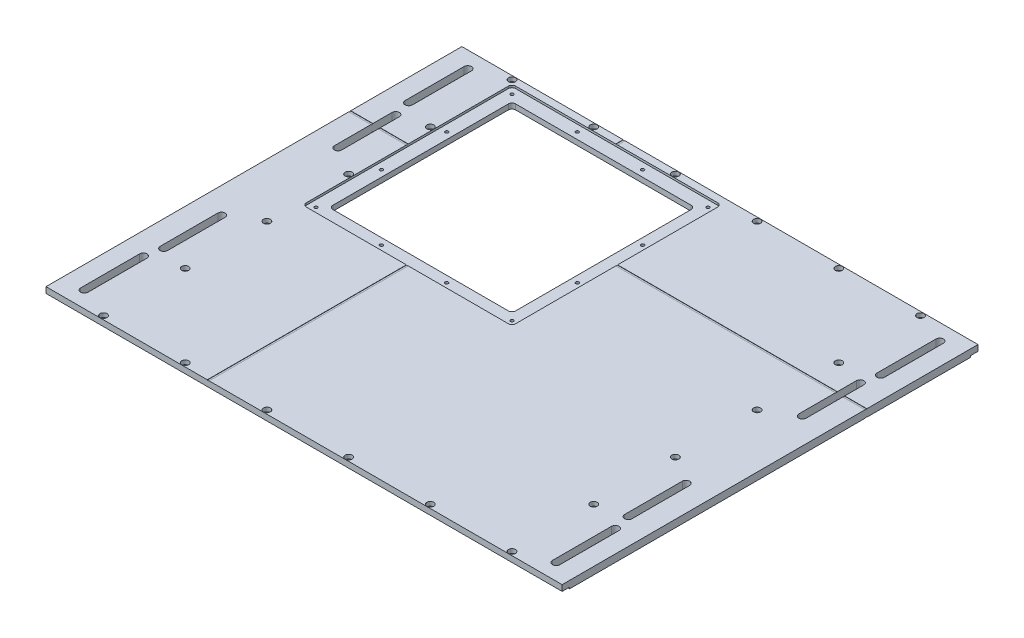
from build123d import *

# Parameters (mm, degrees)
SKETCH1_W                                      = 444.5
SKETCH1_H                                      = 358.14
BOSS_EXTRUDE1_DEPTH                            = 6.35
CUT_EXTRUDE1_DEPTH                             = 6.35
CUT_EXTRUDE2_DEPTH                             = 1.8542
CBORE_FOR_6_SOCKET_HEAD_CAP_SCREW1_D           = 3.6576
CBORE_FOR_6_SOCKET_HEAD_CAP_SCREW1_CBORE_D     = 5.999999938
CBORE_FOR_6_SOCKET_HEAD_CAP_SCREW1_CBORE_DEPTH = 3.5052
TAP_DRILL_FOR_6_32_TAP1_D                      = 2.7051
SKETCH21_W                                     = 345.44
SKETCH21_H                                     = 345.44
CUT_EXTRUDE3_DEPTH                             = 1.27
CUT_EXTRUDE4_DEPTH                             = 7.35
CUT_EXTRUDE6_DEPTH                             = 0.254
CUT_EXTRUDE7_DEPTH                             = 0.254


with BuildPart() as part:
    # Sketch1 → Boss-Extrude1 (new body)
    with BuildSketch(Plane(origin=(0, 0, 0), x_dir=(1, 0, 0), z_dir=(0, 1, 0))):
        with Locations((222.25, 179.07)):
            Rectangle(SKETCH1_W, SKETCH1_H)
    extrude(amount=BOSS_EXTRUDE1_DEPTH)

    # Sketch2 → Cut-Extrude1 (cut)
    with BuildSketch(Plane(origin=(0, 6.35, 0), x_dir=(1, 0, 0), z_dir=(0, 1, 0))):
        with BuildLine():
            Line((64.135, 182.88), (215.265, 182.88))
            ThreePointArc((215.265, 182.88), (217.51006403, 183.80993597), (218.44, 186.055))
            Line((218.44, 186.055), (218.44, 337.185))
            ThreePointArc((218.44, 337.185), (217.51006403, 339.43006403), (215.265, 340.36))
            Line((215.265, 340.36), (64.135, 340.36))
            ThreePointArc((64.135, 340.36), (61.88993597, 339.43006403), (60.96, 337.185))
            Line((60.96, 337.185), (60.96, 186.055))
            ThreePointArc((60.96, 186.055), (61.88993597, 183.80993597), (64.135, 182.88))
        make_face()
    extrude(amount=-CUT_EXTRUDE1_DEPTH, mode=Mode.SUBTRACT)

    # Sketch3 → Cut-Extrude2 (cut)
    with BuildSketch(Plane(origin=(0, 6.35, 0), x_dir=(1, 0, 0), z_dir=(0, 1, 0))):
        with BuildLine():
            Line((52.705, 171.45), (226.695, 171.45))
            ThreePointArc((226.695, 171.45), (228.94006403, 172.37993597), (229.87, 174.625))
            Line((229.87, 174.625), (229.87, 348.615))
            ThreePointArc((229.87, 348.615), (228.94006403, 350.86006403), (226.695, 351.79))
            Line((226.695, 351.79), (52.705, 351.79))
            ThreePointArc((52.705, 351.79), (50.45993597, 350.86006403), (49.53, 348.615))
            Line((49.53, 348.615), (49.53, 174.625))
            ThreePointArc((49.53, 174.625), (50.45993597, 172.37993597), (52.705, 171.45))
        make_face()
    extrude(amount=-CUT_EXTRUDE2_DEPTH, mode=Mode.SUBTRACT)

    # CBORE for #6 Socket Head Cap Screw1 (through all)
    with Locations(Plane(origin=(0, 6.35, 0), x_dir=(1, 0, 0), z_dir=(0, 1, 0))):
        with Locations((46.355, 354.965), (116.713, 354.965), (187.071, 354.965), (398.145, 354.965), (327.787, 354.965), (257.429, 354.965), (398.145, 3.175), (327.787, 3.175), (257.429, 3.175), (187.071, 3.175), (116.713, 3.175), (46.355, 3.175), (398.145, 284.607), (398.145, 214.249), (398.145, 143.891), (398.145, 73.533), (46.355, 73.533), (46.355, 143.891), (46.355, 214.249), (46.355, 284.607)):
            CounterBoreHole(CBORE_FOR_6_SOCKET_HEAD_CAP_SCREW1_D / 2, CBORE_FOR_6_SOCKET_HEAD_CAP_SCREW1_CBORE_D / 2, CBORE_FOR_6_SOCKET_HEAD_CAP_SCREW1_CBORE_DEPTH)

    # Tap Drill for #6-32 Tap1 (through all)
    with Locations(Plane(origin=(249.462488364, 4.4958, -88.952448836), x_dir=(0, 0, 1), z_dir=(0, 1, 0))):
        with Locations((-257.059051164, -194.153988364), (-88.276051164, -194.153988364), (-144.537051164, -194.153988364), (-200.798051164, -194.153988364), (-257.059051164, -137.892988364), (-88.276051164, -137.892988364), (-88.276051164, -81.631988364), (-88.276051164, -25.370988364), (-144.537051164, -25.370988364), (-200.798051164, -25.370988364), (-257.059051164, -25.370988364), (-257.059051164, -81.631988364)):
            Hole(TAP_DRILL_FOR_6_32_TAP1_D / 2)

    # Sketch21 → Cut-Extrude3 (cut)
    with BuildSketch(Plane.XZ):
        Polygon((444.5, -358.14), (444.5, -351.79), (401.32, -351.79), (401.32, -6.35), (444.5, -6.35), (444.5, 0), (0, 0), (0, -6.35), (43.18, -6.35), (43.18, -351.79), (0, -351.79), (0, -358.14), align=None)
        with Locations((222.25, -179.07)):
            Rectangle(SKETCH21_W, SKETCH21_H, mode=Mode.SUBTRACT)
    extrude(amount=-CUT_EXTRUDE3_DEPTH, mode=Mode.SUBTRACT)

    # Sketch22 → Cut-Extrude4 (cut, through all)
    with BuildSketch(Plane.XZ):
        with BuildLine():
            Line((22.2504, -13.97), (22.2504, -64.77))
            ThreePointArc((22.2504, -64.77), (19.05, -67.9704), (15.8496, -64.77))
            Line((15.8496, -64.77), (15.8496, -13.97))
            ThreePointArc((15.8496, -13.97), (19.05, -10.7696), (22.2504, -13.97))
        make_face()
        with BuildLine():
            Line((425.425, -79.2415), (425.425, -128.8985))
            ThreePointArc((425.425, -128.8985), (422.25, -132.0735), (419.075, -128.8985))
            Line((419.075, -128.8985), (419.075, -79.2415))
            ThreePointArc((419.075, -79.2415), (422.25, -76.0665), (425.425, -79.2415))
        make_face()
        with BuildLine():
            Line((22.2504, -344.17), (22.2504, -293.37))
            ThreePointArc((22.2504, -293.37), (19.05, -290.1696), (15.8496, -293.37))
            Line((15.8496, -293.37), (15.8496, -344.17))
            ThreePointArc((15.8496, -344.17), (19.05, -347.3704), (22.2504, -344.17))
        make_face()
        with BuildLine():
            Line((422.2496, -13.97), (422.2496, -64.77))
            ThreePointArc((422.2496, -64.77), (425.45, -67.9704), (428.6504, -64.77))
            Line((428.6504, -64.77), (428.6504, -13.97))
            ThreePointArc((428.6504, -13.97), (425.45, -10.7696), (422.2496, -13.97))
        make_face()
        with BuildLine():
            Line((422.2496, -344.17), (422.2496, -293.37))
            ThreePointArc((422.2496, -293.37), (425.45, -290.1696), (428.6504, -293.37))
            Line((428.6504, -293.37), (428.6504, -344.17))
            ThreePointArc((428.6504, -344.17), (425.45, -347.3704), (422.2496, -344.17))
        make_face()
        with BuildLine():
            Line((19.075, -79.2415), (19.075, -128.8985))
            ThreePointArc((19.075, -128.8985), (22.25, -132.0735), (25.425, -128.8985))
            Line((25.425, -128.8985), (25.425, -79.2415))
            ThreePointArc((25.425, -79.2415), (22.25, -76.0665), (19.075, -79.2415))
        make_face()
        with BuildLine():
            Line((19.075, -278.8985), (19.075, -229.2415))
            ThreePointArc((19.075, -229.2415), (22.25, -226.0665), (25.425, -229.2415))
            Line((25.425, -229.2415), (25.425, -278.8985))
            ThreePointArc((25.425, -278.8985), (22.25, -282.0735), (19.075, -278.8985))
        make_face()
        with BuildLine():
            Line((425.425, -278.8985), (425.425, -229.2415))
            ThreePointArc((425.425, -229.2415), (422.25, -226.0665), (419.075, -229.2415))
            Line((419.075, -229.2415), (419.075, -278.8985))
            ThreePointArc((419.075, -278.8985), (422.25, -282.0735), (425.425, -278.8985))
        make_face()
    extrude(amount=-CUT_EXTRUDE4_DEPTH, mode=Mode.SUBTRACT)

    # Sketch24 → Cut-Extrude6 (cut)
    with BuildSketch(Plane(origin=(0, 6.35, 0), x_dir=(1, 0, 0), z_dir=(0, 1, 0))):
        with BuildLine():
            Line((140.49375, 365.76), (140.49375, 351.806692885))
            Line((140.49375, 351.806692885), (138.90625, 351.806692885))
            Line((138.90625, 351.806692885), (138.90625, 365.76))
            ThreePointArc((138.90625, 365.76), (139.7, 366.55375), (140.49375, 365.76))
        make_face()
        with BuildLine():
            Line((459.740342606, 260.82625), (-0.000342606, 260.82625))
            ThreePointArc((-0.000342606, 260.82625), (-0.794092606, 261.62), (-0.000342606, 262.41375))
            Line((-0.000342606, 262.41375), (459.740342606, 262.41375))
            ThreePointArc((459.740342606, 262.41375), (460.534092606, 261.62), (459.740342606, 260.82625))
        make_face()
        with BuildLine():
            Line((138.90625, 171.45), (140.49375, 171.45))
            Line((140.49375, 171.45), (140.49375, 0))
            ThreePointArc((140.49375, 0), (139.7, -0.79375), (138.90625, 0))
            Line((138.90625, 0), (138.90625, 171.45))
        make_face()
    extrude(amount=-CUT_EXTRUDE6_DEPTH, mode=Mode.SUBTRACT)

    # Sketch25 → Cut-Extrude7 (cut)
    with BuildSketch(Plane.XZ):
        with BuildLine():
            Line((-38.1, -260.82625), (38.1, -260.82625))
            ThreePointArc((38.1, -260.82625), (38.89375, -261.62), (38.1, -262.41375))
            Line((38.1, -262.41375), (-38.1, -262.41375))
            ThreePointArc((-38.1, -262.41375), (-38.89375, -261.62), (-38.1, -260.82625))
        make_face()
        with BuildLine():
            Line((482.6, -262.41375), (406.4, -262.41375))
            ThreePointArc((406.4, -262.41375), (405.60625, -261.62), (406.4, -260.82625))
            Line((406.4, -260.82625), (482.6, -260.82625))
            ThreePointArc((482.6, -260.82625), (483.39375, -261.62), (482.6, -262.41375))
        make_face()
    extrude(amount=-CUT_EXTRUDE7_DEPTH, mode=Mode.SUBTRACT)


solid = part.part
